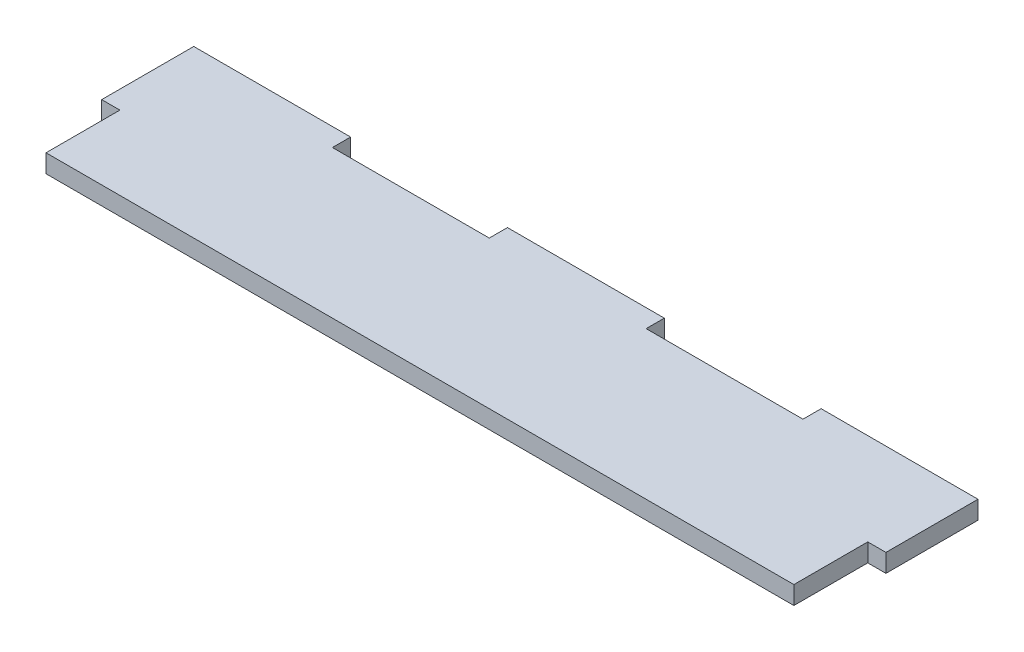
from build123d import *

# Parameters (mm, degrees)
BOSS_EXTRUDE1_DEPTH = 10.16


with BuildPart() as part:
    # Sketch1 → Boss-Extrude1 (new body)
    with BuildSketch(Plane(origin=(0, 0, 0), x_dir=(1, 0, 0), z_dir=(0, 1, 0))):
        Polygon((87.63, 0), (0, 0), (0, -51.435), (10.16, -51.435), (10.16, -92.71), (427.99, -92.71), (427.99, -51.435), (438.15, -51.435), (438.15, 0), (350.52, 0), (350.52, -10.16), (262.89, -10.16), (262.89, 0), (175.26, 0), (175.26, -10.16), (87.63, -10.16), align=None)
    extrude(amount=BOSS_EXTRUDE1_DEPTH)


solid = part.part
